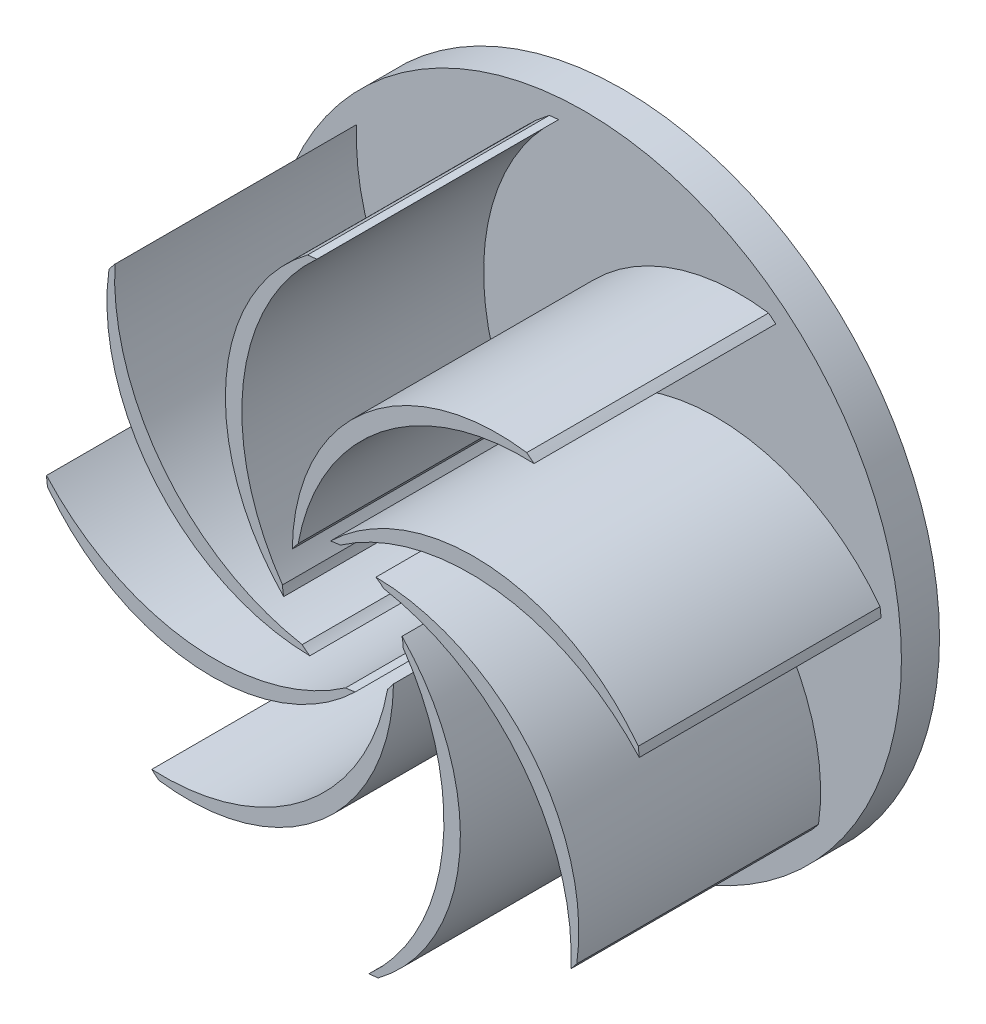
from build123d import *

# Parameters (mm, degrees)
SKETCH1_R           = 33.274
BOSS_EXTRUDE1_DEPTH = 4
SKETCH2_R           = 3.048
CUT_EXTRUDE1_DEPTH  = 5
BOSS_EXTRUDE2_DEPTH = 25.4
SKETCH4_R           = 6.35
CUT_EXTRUDE2_DEPTH  = 56.896
SKETCH5_R           = 33.274
SKETCH5_R_2         = 31.253208268
CUT_EXTRUDE3_DEPTH  = 120.142


with BuildPart() as part:
    # Sketch1 → Boss-Extrude1 (new body)
    with BuildSketch(Plane.XY):
        Circle(SKETCH1_R)
    extrude(amount=BOSS_EXTRUDE1_DEPTH)

    # Sketch2 → Cut-Extrude1 (cut, through all)
    with BuildSketch(Plane.XY.offset(4)):
        Circle(SKETCH2_R)
    extrude(amount=-CUT_EXTRUDE1_DEPTH, mode=Mode.SUBTRACT)

    # Sketch3 → Boss-Extrude2 (add)
    with BuildSketch(Plane.XY.offset(4)):
        with BuildLine():
            ThreePointArc((5.08, 0), (-2.558445785, -19.86901744), (-23.528271037, -23.528271037))
            ThreePointArc((-23.528271037, -23.528271037), (-3.66763311, -18.52034496), (5.08, 0))
        make_face()
        with BuildLine():
            ThreePointArc((3.592102448, -3.592102448), (-15.689269754, -10.502453268), (-33.274, 0))
            ThreePointArc((-33.274, 0), (-15.858611331, -12.240422604), (3.592102448, -3.592102448))
        make_face()
        with BuildLine():
            ThreePointArc((0, -5.08), (-19.86901744, 2.558445785), (-23.528271037, 23.528271037))
            ThreePointArc((-23.528271037, 23.528271037), (-18.52034496, 3.66763311), (0, -5.08))
        make_face()
        with BuildLine():
            ThreePointArc((-3.592102448, -3.592102448), (-12.240422604, 15.858611331), (0, 33.274))
            ThreePointArc((0, 33.274), (-10.502453268, 15.689269754), (-3.592102448, -3.592102448))
        make_face()
        with BuildLine():
            ThreePointArc((-5.08, 0), (2.558445785, 19.86901744), (23.528271037, 23.528271037))
            ThreePointArc((23.528271037, 23.528271037), (3.66763311, 18.52034496), (-5.08, 0))
        make_face()
        with BuildLine():
            ThreePointArc((-3.592102448, 3.592102448), (15.858611331, 12.240422604), (33.274, 0))
            ThreePointArc((33.274, 0), (15.689269754, 10.502453268), (-3.592102448, 3.592102448))
        make_face()
        with BuildLine():
            ThreePointArc((0, 5.08), (19.86901744, -2.558445785), (23.528271037, -23.528271037))
            ThreePointArc((23.528271037, -23.528271037), (18.52034496, -3.66763311), (0, 5.08))
        make_face()
        with BuildLine():
            ThreePointArc((3.592102448, 3.592102448), (12.240422604, -15.858611331), (0, -33.274))
            ThreePointArc((0, -33.274), (10.502453268, -15.689269754), (3.592102448, 3.592102448))
        make_face()
    extrude(amount=BOSS_EXTRUDE2_DEPTH)

    # Sketch4 → Cut-Extrude2 (cut)
    with BuildSketch(Plane.XY.offset(4)):
        Circle(SKETCH4_R)
    extrude(amount=CUT_EXTRUDE2_DEPTH, mode=Mode.SUBTRACT)

    # Sketch5 → Cut-Extrude3 (cut)
    with BuildSketch(Plane.XY.offset(4)):
        Circle(SKETCH5_R)
        Circle(SKETCH5_R_2, mode=Mode.SUBTRACT)
    extrude(amount=CUT_EXTRUDE3_DEPTH, mode=Mode.SUBTRACT)


solid = part.part
